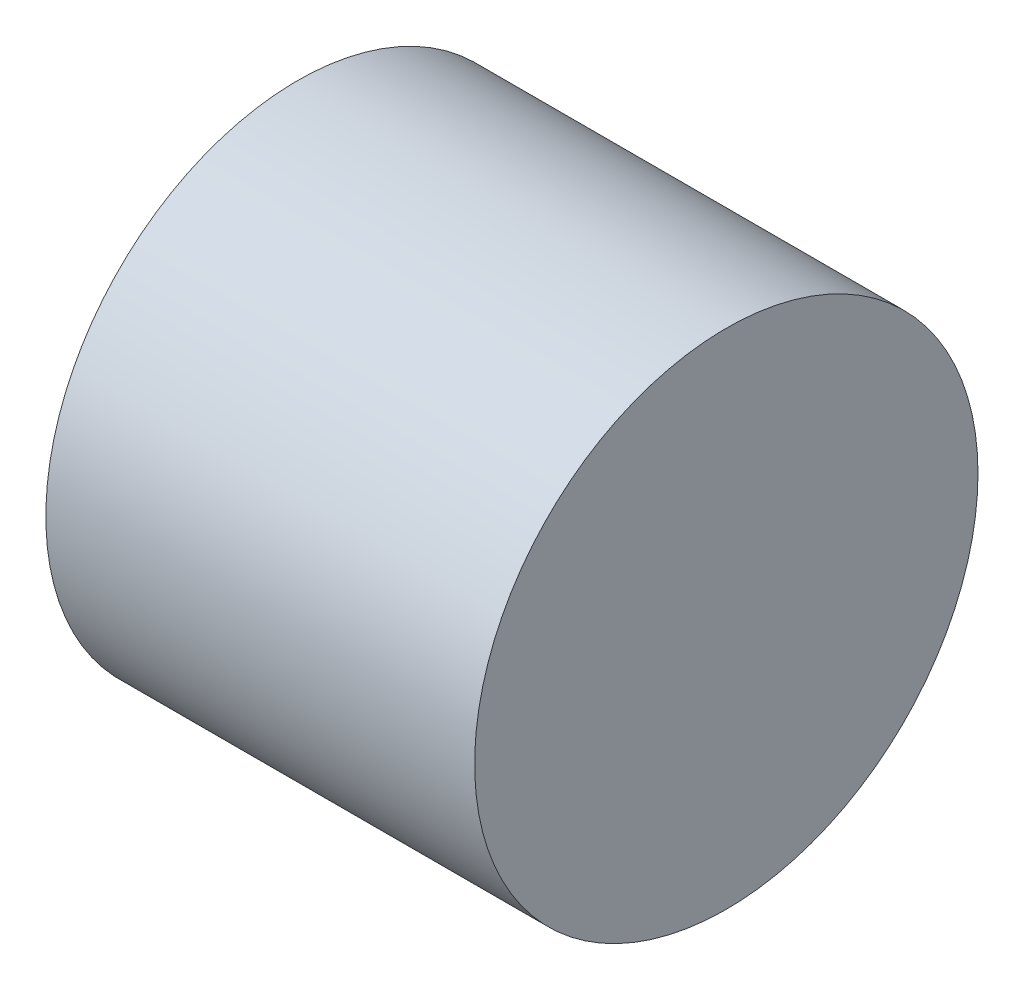
from build123d import *

# Parameters (mm, degrees)
SKETCH1_R           = 27
BOSS_EXTRUDE1_DEPTH = 46


with BuildPart() as part:
    # Sketch1 → Boss-Extrude1 (new body)
    with BuildSketch(Plane(origin=(0, 0, 0), x_dir=(0, 0, -1), z_dir=(1, 0, 0))):
        Circle(SKETCH1_R)
    extrude(amount=BOSS_EXTRUDE1_DEPTH)


solid = part.part
